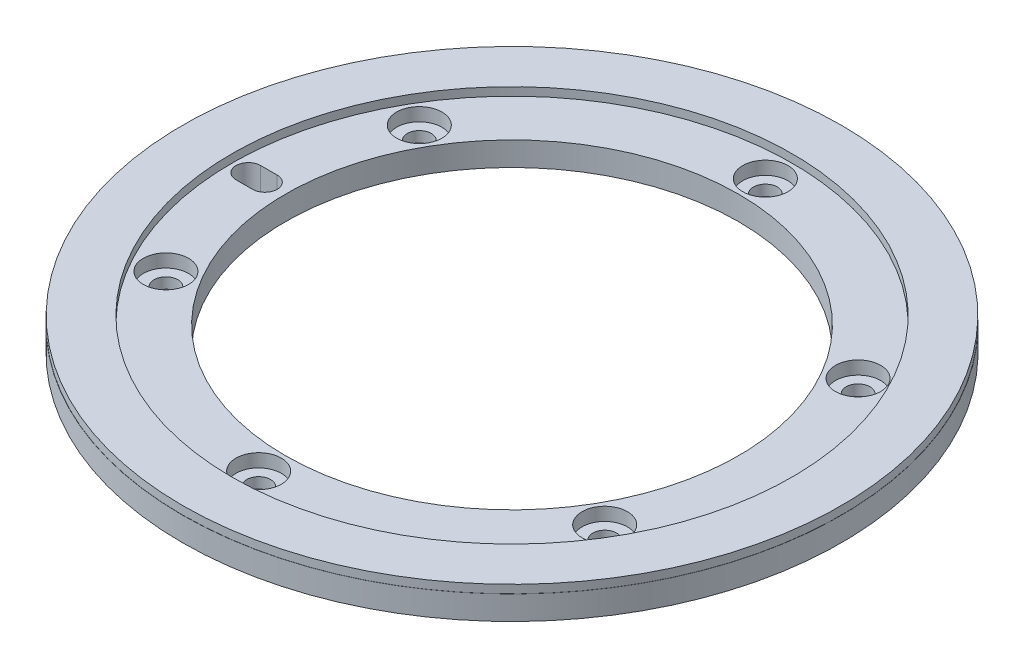
from build123d import *

# Parameters (mm, degrees)
SKETCH1_W                                            = 12.5
SKETCH1_H                                            = 2.9
CBORE_FOR_M2_5_HEX_SOCKET_HEAD_CAP_SCREW_D           = 2.9
CBORE_FOR_M2_5_HEX_SOCKET_HEAD_CAP_SCREW_CBORE_D     = 5.5
CBORE_FOR_M2_5_HEX_SOCKET_HEAD_CAP_SCREW_CBORE_DEPTH = 2.1
CIRPATTERN1_COUNT                                    = 6
CUT_EXTRUDE4_DEPTH                                   = 10
SKETCH5_R                                            = 39.98
SKETCH5_R_2                                          = 34
BOSS_EXTRUDE1_DEPTH                                  = 1


with BuildPart() as part:
    # Sketch1 → Revolve1 (revolve)
    with BuildSketch(Plane.XY):
        with Locations((-33.75, 1.45)):
            Rectangle(SKETCH1_W, SKETCH1_H)
    revolve(axis=Axis((0, -3.243860323, 0), (0, 1, 0)))

    # CBORE for M2.5 Hex Socket Head Cap Screw2 (through all)
    with Locations(Plane(origin=(0, 3.4, 0), x_dir=(-1, 0, 0), z_dir=(0, 1, 0))):
        with Locations((0, -30.75)):
            cbore_for_m2_5_hex_socket_head_cap_screw = CounterBoreHole(CBORE_FOR_M2_5_HEX_SOCKET_HEAD_CAP_SCREW_D / 2, CBORE_FOR_M2_5_HEX_SOCKET_HEAD_CAP_SCREW_CBORE_D / 2, CBORE_FOR_M2_5_HEX_SOCKET_HEAD_CAP_SCREW_CBORE_DEPTH)

    # CirPattern1: CBORE for M2.5 Hex Socket Head Cap Screw2 ×6 about axis
    cirpattern1_axis = Axis((0, 0, 0), (0, 1, 0))
    for i in range(1, CIRPATTERN1_COUNT):
        add(cbore_for_m2_5_hex_socket_head_cap_screw.rotate(cirpattern1_axis, i * 360 / CIRPATTERN1_COUNT), mode=Mode.SUBTRACT)

    # Sketch10 → Cut-Extrude4 (cut)
    with BuildSketch(Plane(origin=(0, 2.9, 0), x_dir=(1, 0, 0), z_dir=(0, 1, 0))):
        with BuildLine():
            Line((-32, 1.5), (-30, 1.5))
            ThreePointArc((-30, 1.5), (-28.5, 0), (-30, -1.5))
            Line((-30, -1.5), (-32, -1.5))
            ThreePointArc((-32, -1.5), (-33.5, 0), (-32, 1.5))
        make_face()
    extrude(amount=-CUT_EXTRUDE4_DEPTH, mode=Mode.SUBTRACT)

    # Sketch5 → Boss-Extrude1 (add)
    with BuildSketch(Plane(origin=(0, 2.9, 0), x_dir=(1, 0, 0), z_dir=(0, 1, 0))):
        Circle(SKETCH5_R)
        Circle(SKETCH5_R_2, mode=Mode.SUBTRACT)
    extrude(amount=BOSS_EXTRUDE1_DEPTH)


solid = part.part
